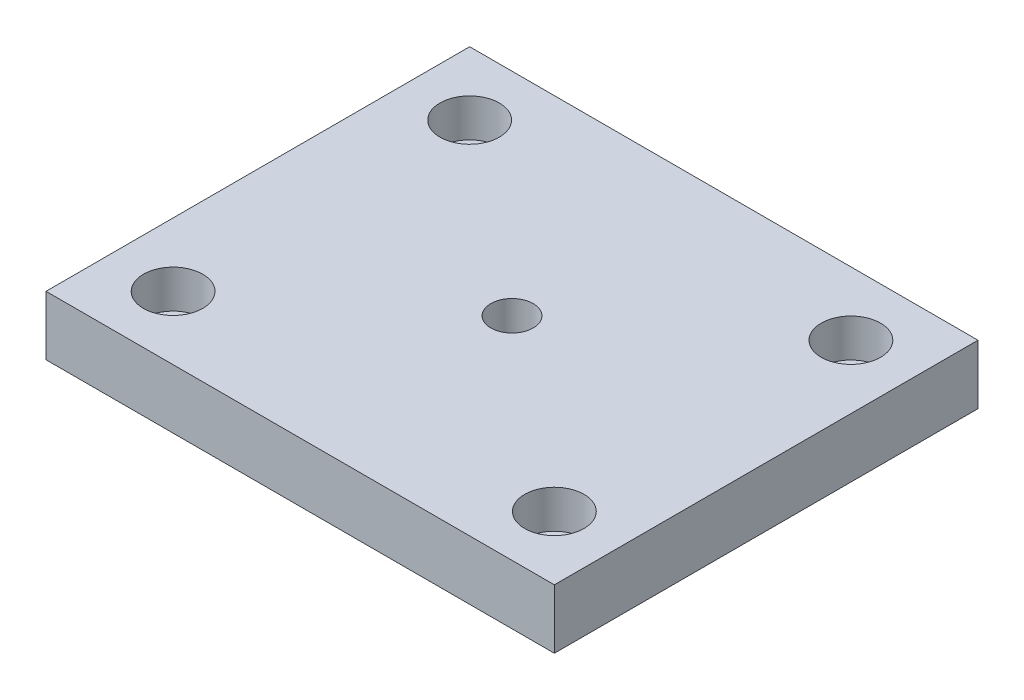
from build123d import *

# Parameters (mm, degrees)
ESBO_O1_W                         = 120
ESBO_O1_H                         = 100
ESBO_O1_R                         = 5
RESSALTO_EXTRUS_O1_DEPTH          = 14
REBAIXO_PARA_SHCS_M81_D           = 9
REBAIXO_PARA_SHCS_M81_CBORE_D     = 14
REBAIXO_PARA_SHCS_M81_CBORE_DEPTH = 9


with BuildPart() as part:
    # Esboço1 → Ressalto-extrusão1 (new body)
    with BuildSketch(Plane(origin=(0, 0, 0), x_dir=(1, 0, 0), z_dir=(0, 1, 0))):
        Rectangle(ESBO_O1_W, ESBO_O1_H)
        with Locations(Location((0, 0, 0), (0, 0, 270))):  # turned: the seam where the file's is
            Circle(ESBO_O1_R, mode=Mode.SUBTRACT)
    extrude(amount=RESSALTO_EXTRUS_O1_DEPTH)

    # Rebaixo para SHCS M81 (through all)
    with Locations(Plane(origin=(0, 14, 0), x_dir=(-1, 0, 0), z_dir=(0, 1, 0))):
        with Locations((45, -35), (45, 35), (-45, 35), (-45, -35)):
            CounterBoreHole(REBAIXO_PARA_SHCS_M81_D / 2, REBAIXO_PARA_SHCS_M81_CBORE_D / 2, REBAIXO_PARA_SHCS_M81_CBORE_DEPTH)


solid = part.part
